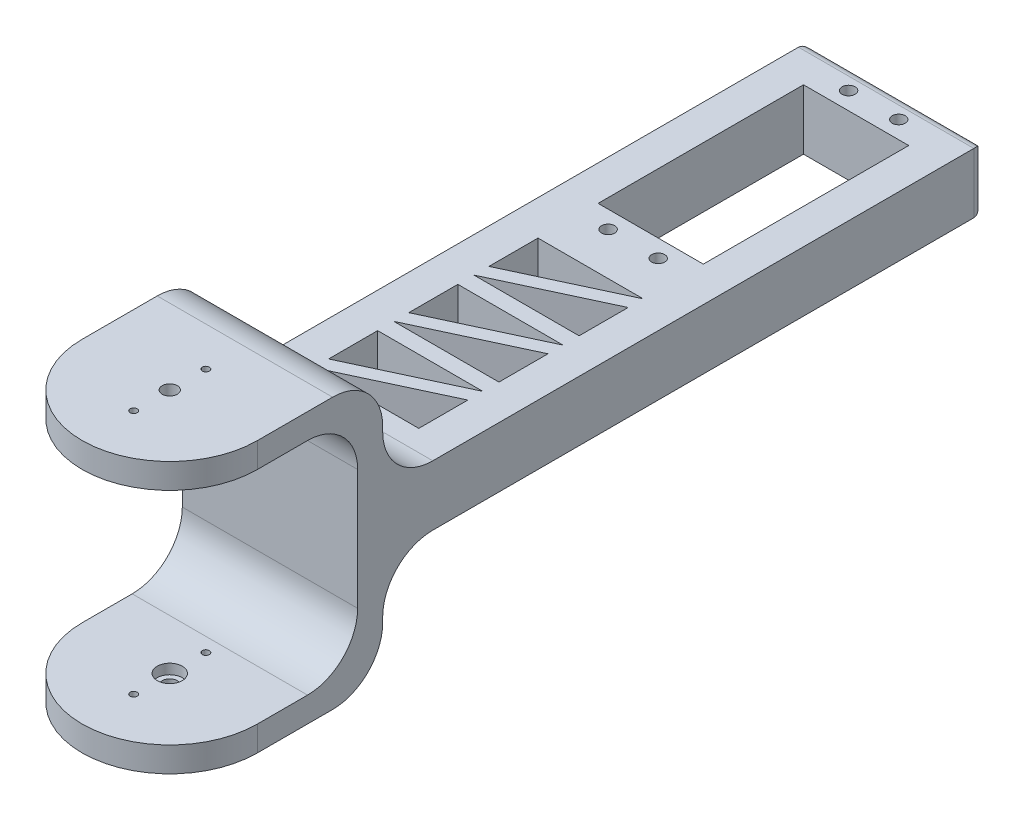
from build123d import *

# Parameters (mm, degrees)
SKETCH1_R           = 17.5
SKETCH1_R_2         = 1.5
BOSS_EXTRUDE1_DEPTH = 5
SKETCH3_R           = 1.5
BOSS_EXTRUDE2_DEPTH = 5
SKETCH4_W           = 35
SKETCH4_H           = 54
BOSS_EXTRUDE3_DEPTH = 5
FILLET1_R           = 10
SKETCH6_W           = 35
SKETCH6_H           = 12
BOSS_EXTRUDE4_DEPTH = 120
CUT_EXTRUDE1_REACH  = 35
SKETCH7_R           = 1.3
SKETCH7_W           = 21
SKETCH7_H           = 41
CUT_EXTRUDE2_DEPTH  = 12
LPATTERN1_COUNT     = 3
LPATTERN1_PITCH     = 16
FILLET2_R           = 10
FILLET3_R           = 2
SKETCH11_R          = 0.7
SKETCH11_R_2        = 1.5
CUT_EXTRUDE3_DEPTH  = 55
SKETCH12_R          = 2.5
CUT_EXTRUDE4_DEPTH  = 2
SKETCH13_R          = 2.5
CUT_EXTRUDE5_DEPTH  = 2


with BuildPart() as part:
    # Sketch1 → Boss-Extrude1 (new body)
    with BuildSketch(Plane(origin=(0, 0, 0), x_dir=(1, 0, 0), z_dir=(0, 1, 0))):
        Circle(SKETCH1_R)
        Circle(SKETCH1_R_2, mode=Mode.SUBTRACT)
        with BuildLine():
            Line((-17.5, 20), (-17.5, 0))
            ThreePointArc((-17.5, 0), (0, 17.5), (17.5, 0))
            Line((17.5, 0), (17.5, 20))
            Line((17.5, 20), (-17.5, 20))
        make_face()
    extrude(amount=BOSS_EXTRUDE1_DEPTH)



with BuildPart() as body_2:
    # Sketch3 → Boss-Extrude2 (new body)
    with BuildSketch(Plane(origin=(0, -49, 0), x_dir=(1, 0, 0), z_dir=(0, 1, 0))):
        with BuildLine():
            Line((17.5, 0), (17.5, 20))
            Line((17.5, 20), (-17.5, 20))
            Line((-17.5, 20), (-17.5, 0))
            ThreePointArc((-17.5, 0), (0, -17.5), (17.5, 0))
        make_face()
        Circle(SKETCH3_R, mode=Mode.SUBTRACT)
    extrude(amount=BOSS_EXTRUDE2_DEPTH)


with BuildPart() as part_1:
    add(part.part)

    add(body_2.part)  # Boss-Extrude3 merges body 2
    # Sketch4 → Boss-Extrude3 (add)
    with BuildSketch(Plane(origin=(0, 0, -20), x_dir=(-1, 0, 0), z_dir=(0, 0, -1))):
        with Locations((0, -22)):
            Rectangle(SKETCH4_W, SKETCH4_H)
    extrude(amount=BOSS_EXTRUDE3_DEPTH)

    # Fillet1
    fillet1_edges = [part_1.edges().sort_by_distance(p)[0] for p in [
        (0, -49, -25),
        (0, 5, -25),
        (0, -44, -20),
        (0, 0, -20),
    ]]
    fillet(fillet1_edges, radius=FILLET1_R)

    # Sketch6 → Boss-Extrude4 (add)
    with BuildSketch(Plane(origin=(0, 0, -25), x_dir=(-1, 0, 0), z_dir=(0, 0, -1))):
        with Locations((0, -22)):
            Rectangle(SKETCH6_W, SKETCH6_H)
    extrude(amount=BOSS_EXTRUDE4_DEPTH)

    # Sketch7 → Cut-Extrude1 (cut, up to next)
    with BuildSketch(Plane(origin=(0, -16, 0), x_dir=(1, 0, 0), z_dir=(0, 1, 0)), mode=Mode.PRIVATE) as cut_extrude1_sk1:
        with Locations((-5, 140.5)):
            Circle(SKETCH7_R)
    cut_extrude1_tool1 = extrude(cut_extrude1_sk1.sketch, amount=-CUT_EXTRUDE1_REACH, mode=Mode.PRIVATE) & part_1.part
    add(cut_extrude1_tool1.solids().sort_by_distance((-5, -16, -140.5))[0], mode=Mode.SUBTRACT)
    # Sketch7 → Cut-Extrude1 (cut, up to next)
    with BuildSketch(Plane(origin=(0, -16, 0), x_dir=(1, 0, 0), z_dir=(0, 1, 0)), mode=Mode.PRIVATE) as cut_extrude1_sk2:
        with Locations((5, 140.5)):
            Circle(SKETCH7_R)
    cut_extrude1_tool2 = extrude(cut_extrude1_sk2.sketch, amount=-CUT_EXTRUDE1_REACH, mode=Mode.PRIVATE) & part_1.part
    add(cut_extrude1_tool2.solids().sort_by_distance((5, -16, -140.5))[0], mode=Mode.SUBTRACT)
    # Sketch7 → Cut-Extrude1 (cut, up to next)
    with BuildSketch(Plane(origin=(0, -16, 0), x_dir=(1, 0, 0), z_dir=(0, 1, 0)), mode=Mode.PRIVATE) as cut_extrude1_sk3:
        with Locations((5, 92.5)):
            Circle(SKETCH7_R)
    cut_extrude1_tool3 = extrude(cut_extrude1_sk3.sketch, amount=-CUT_EXTRUDE1_REACH, mode=Mode.PRIVATE) & part_1.part
    add(cut_extrude1_tool3.solids().sort_by_distance((5, -16, -92.5))[0], mode=Mode.SUBTRACT)
    # Sketch7 → Cut-Extrude1 (cut, up to next)
    with BuildSketch(Plane(origin=(0, -16, 0), x_dir=(1, 0, 0), z_dir=(0, 1, 0)), mode=Mode.PRIVATE) as cut_extrude1_sk4:
        with Locations((-5, 92.5)):
            Circle(SKETCH7_R)
    cut_extrude1_tool4 = extrude(cut_extrude1_sk4.sketch, amount=-CUT_EXTRUDE1_REACH, mode=Mode.PRIVATE) & part_1.part
    add(cut_extrude1_tool4.solids().sort_by_distance((-5, -16, -92.5))[0], mode=Mode.SUBTRACT)
    # Sketch7 → Cut-Extrude1 (cut, up to next)
    with BuildSketch(Plane(origin=(0, -16, 0), x_dir=(1, 0, 0), z_dir=(0, 1, 0)), mode=Mode.PRIVATE) as cut_extrude1_sk5:
        with Locations((0, 116.5)):
            Rectangle(SKETCH7_W, SKETCH7_H)
    cut_extrude1_tool5 = extrude(cut_extrude1_sk5.sketch, amount=-CUT_EXTRUDE1_REACH, mode=Mode.PRIVATE) & part_1.part
    add(cut_extrude1_tool5.solids().sort_by_distance((0, -16, -116.5))[0], mode=Mode.SUBTRACT)

    # Sketch8 → Cut-Extrude2 (cut)
    with BuildSketch(Plane(origin=(0, -16, 0), x_dir=(1, 0, 0), z_dir=(0, 1, 0))):
        Polygon((10.5, 84), (-10.5, 84), (-10.5, 74.207539179), align=None)
        Polygon((10.5, 71.207539179), (10.5, 81), (-10.5, 71.207539179), align=None)
    cut_extrude2 = extrude(amount=-CUT_EXTRUDE2_DEPTH, mode=Mode.SUBTRACT)

    # LPattern1: Cut-Extrude2 ×3
    with Locations(*[(0, 0, i * LPATTERN1_PITCH) for i in range(1, LPATTERN1_COUNT)]):
        add(cut_extrude2, mode=Mode.SUBTRACT)

    # Fillet2
    fillet2_edges = [part_1.edges().sort_by_distance(p)[0] for p in [
        (0, -28, -25),
        (0, -16, -25),
    ]]
    fillet(fillet2_edges, radius=FILLET2_R)

    # Fillet3
    fillet3_edges = [part_1.edges().sort_by_distance(p)[0] for p in [
        (17.5, -22, -145),
        (0, -28, -145),
        (-17.5, -22, -145),
        (0, -16, -145),
    ]]
    fillet(fillet3_edges, radius=FILLET3_R)

    # Sketch11 → Cut-Extrude3 (cut, through all)
    with BuildSketch(Plane(origin=(0, 5, 0), x_dir=(1, 0, 0), z_dir=(0, 1, 0))):
        with Locations((0, 7.2)):
            Circle(SKETCH11_R)
        Circle(SKETCH11_R_2)
        with Locations((0, -7.2)):
            Circle(SKETCH11_R)
    extrude(amount=-CUT_EXTRUDE3_DEPTH, mode=Mode.SUBTRACT)

    # Sketch12 → Cut-Extrude4 (cut)
    with BuildSketch(Plane.XZ):
        Circle(SKETCH12_R)
    extrude(amount=-CUT_EXTRUDE4_DEPTH, mode=Mode.SUBTRACT)

    # Sketch13 → Cut-Extrude5 (cut)
    with BuildSketch(Plane(origin=(0, -44, 0), x_dir=(1, 0, 0), z_dir=(0, 1, 0))):
        Circle(SKETCH13_R)
    extrude(amount=-CUT_EXTRUDE5_DEPTH, mode=Mode.SUBTRACT)


solid = part_1.part
